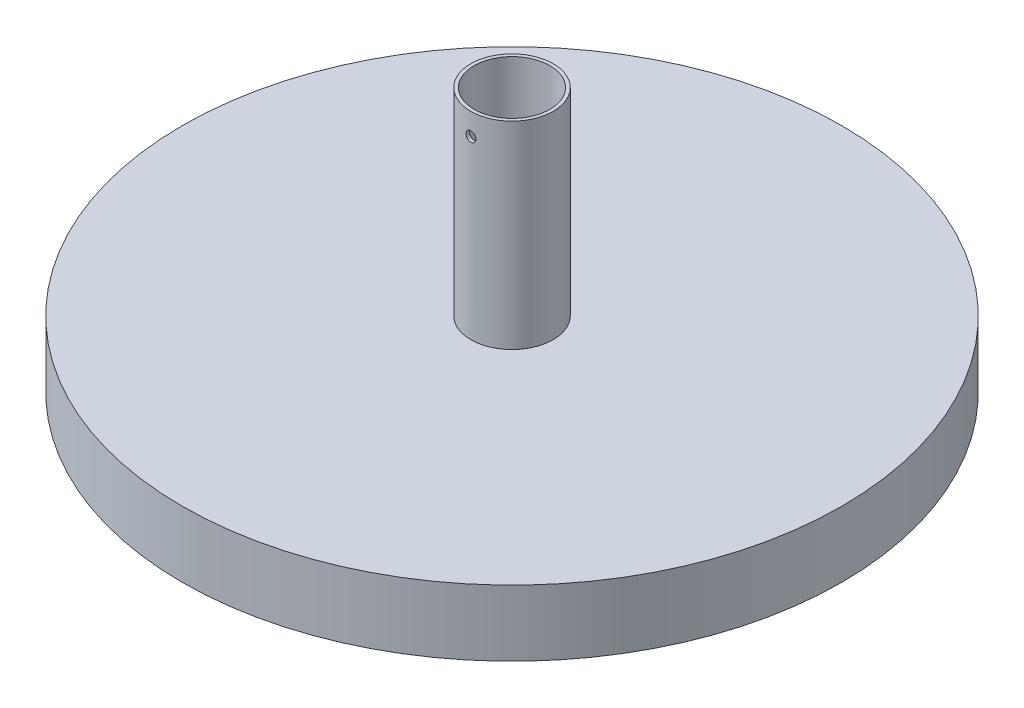
from build123d import *

# Parameters (mm, degrees)
SKETCH1_R           = 100
BOSS_EXTRUDE1_DEPTH = 20
SKETCH2_R           = 12.5
SKETCH2_R_2         = 11.5
BOSS_EXTRUDE2_DEPTH = 60
CUT_EXTRUDE1_REACH  = 102
SKETCH3_R           = 1.5


with BuildPart() as part:
    # Sketch1 → Boss-Extrude1 (new body)
    with BuildSketch(Plane(origin=(0, 0, 0), x_dir=(1, 0, 0), z_dir=(0, 1, 0))):
        Circle(SKETCH1_R)
    extrude(amount=BOSS_EXTRUDE1_DEPTH)

    # Sketch2 → Boss-Extrude2 (add)
    with BuildSketch(Plane(origin=(0, 20, 0), x_dir=(1, 0, 0), z_dir=(0, 1, 0))):
        Circle(SKETCH2_R)
        Circle(SKETCH2_R_2, mode=Mode.SUBTRACT)
    extrude(amount=BOSS_EXTRUDE2_DEPTH)

    # Sketch3 → Cut-Extrude1 (cut, up to next)
    with BuildSketch(Plane.XY, mode=Mode.PRIVATE) as cut_extrude1_sk1:
        with Locations((0, 73.383174369)):
            Circle(SKETCH3_R)
    cut_extrude1_tool1 = extrude(cut_extrude1_sk1.sketch, amount=CUT_EXTRUDE1_REACH, mode=Mode.PRIVATE) & part.part
    add(cut_extrude1_tool1.solids().sort_by_distance((0, 73.383174, 0))[0], mode=Mode.SUBTRACT)


solid = part.part
